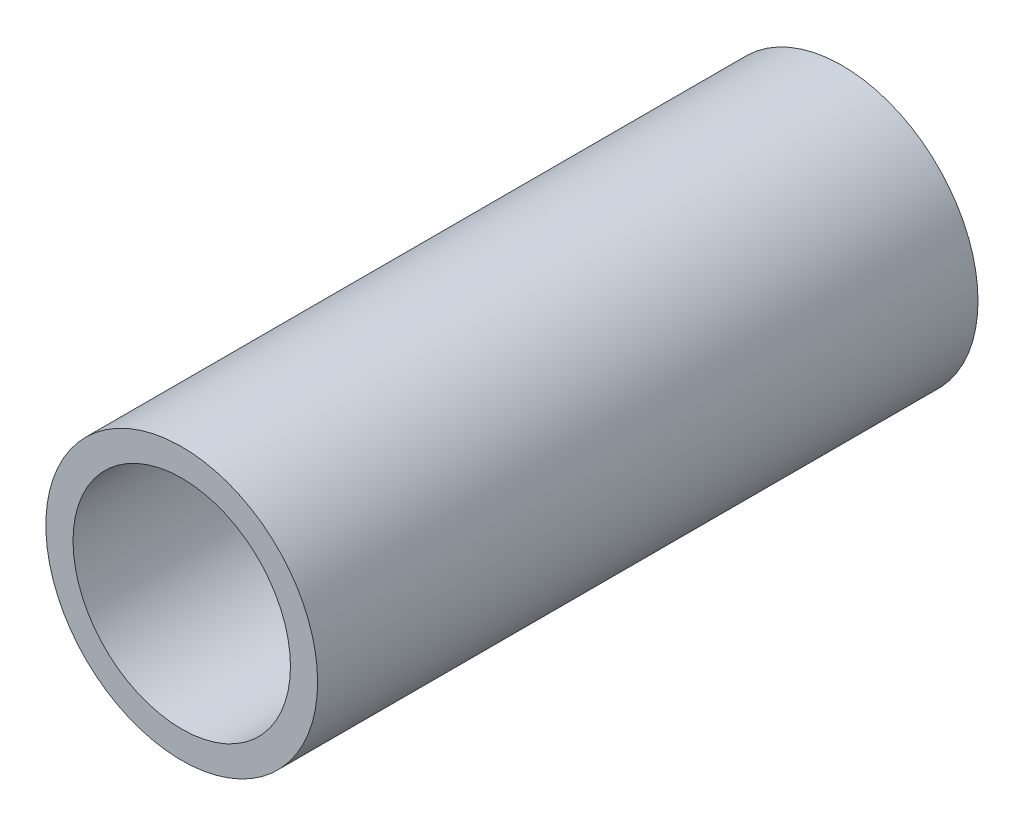
from build123d import *

# Parameters (mm, degrees)
SKETCH1_R           = 2.5
SKETCH1_R_2         = 2
BOSS_EXTRUDE1_DEPTH = 12.15


with BuildPart() as part:
    # Sketch1 → Boss-Extrude1 (new body)
    with BuildSketch(Plane.XY):
        Circle(SKETCH1_R)
        Circle(SKETCH1_R_2, mode=Mode.SUBTRACT)
    extrude(amount=BOSS_EXTRUDE1_DEPTH)


solid = part.part
